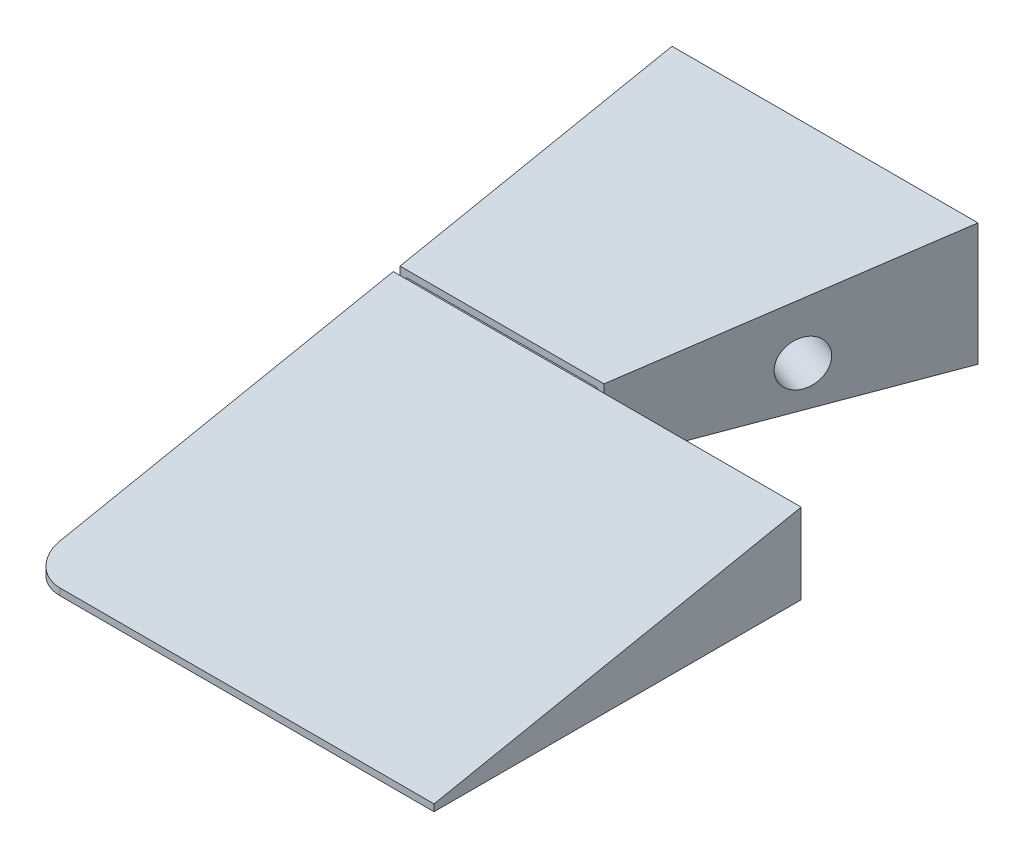
from build123d import *

# Parameters (mm, degrees)
ESBO_O1_W                                      = 130
ESBO_O1_H                                      = 20
RESSALTO_EXTRUS_O1_DEPTH                       = 95
CORTE_EXTRUS_O2_REACH                          = 22
CORTE_EXTRUS_O4_DEPTH                          = 1
CORTE_EXTRUS_O4_DEPTH_BACK                     = 61
BROCA_DE_ROSQUEAR_DE_CANO_PARA_TARRAXA_D_D     = 6.579997
BROCA_DE_ROSQUEAR_DE_CANO_PARA_TARRAXA_D_DEPTH = 10
BROCA_DE_ROSQUEAR_DE_CANO_PARA_TARRAXA_D_TIP   = 1.976830535
BROCA_DE_ROSQUEAR_DE_CANO_PARA_TARRA_2_D       = 6.579997
BROCA_DE_ROSQUEAR_DE_CANO_PARA_TARRA_2_DEPTH   = 10
BROCA_DE_ROSQUEAR_DE_CANO_PARA_TARRA_2_TIP     = 1.976830535
FILETE2_R                                      = 5
CORTE_EXTRUS_O10_REACH                         = 62
RESSALTO_EXTRUS_O2_REACH                       = 57
ESBO_O41_W                                     = 28
ESBO_O41_H                                     = 8
ESBO_O42_W                                     = 45
ESBO_O42_H                                     = 2
CORTE_EXTRUS_O11_DEPTH                         = 41


with BuildPart() as part:
    # Esboço1 → Ressalto-extrusão1 (new body)
    with BuildSketch(Plane.XY):
        Rectangle(ESBO_O1_W, ESBO_O1_H)
    extrude(amount=RESSALTO_EXTRUS_O1_DEPTH)

    # Esboço2 → Corte-extrusão2 (cut, up to next)
    with BuildSketch(Plane(origin=(0, 10, 0), x_dir=(1, 0, 0), z_dir=(0, 1, 0)), mode=Mode.PRIVATE) as corte_extrus_o2_sk1:
        Polygon((65, 0), (-20, 0), (-35, -40), (-35, -41), (-5, -41), (-5, -95), (65, -95), align=None)
    corte_extrus_o2_tool1 = extrude(corte_extrus_o2_sk1.sketch, amount=-CORTE_EXTRUS_O2_REACH, mode=Mode.PRIVATE) & part.part
    add(corte_extrus_o2_tool1.solids().sort_by_distance((24.261214, 10, 44.470976))[0], mode=Mode.SUBTRACT)

    # Esboço13 → Corte-extrusão4 (cut, two sides)
    with BuildSketch(Plane.ZY.offset(65)) as corte_extrus_o4_sk:
        Polygon((-200.200134404, 50.040026881), (0, 10), (95, -9), (295.200134404, -49.040026881), (375.280188165, 351.360241926), (-120.120080642, 450.440295688), align=None)
    extrude(amount=CORTE_EXTRUS_O4_DEPTH, mode=Mode.SUBTRACT)
    extrude(corte_extrus_o4_sk.sketch, amount=-CORTE_EXTRUS_O4_DEPTH_BACK, mode=Mode.SUBTRACT)

    # Broca de rosquear de cano para tarraxa d
    with Locations(Plane.ZY.offset(65)):
        with Locations((20, -2)):
            Hole(BROCA_DE_ROSQUEAR_DE_CANO_PARA_TARRAXA_D_D / 2, depth=BROCA_DE_ROSQUEAR_DE_CANO_PARA_TARRAXA_D_DEPTH)
            with Locations((0, 0, -(BROCA_DE_ROSQUEAR_DE_CANO_PARA_TARRAXA_D_DEPTH + BROCA_DE_ROSQUEAR_DE_CANO_PARA_TARRAXA_D_TIP / 2))):  # 118° drill point
                Cone(0, BROCA_DE_ROSQUEAR_DE_CANO_PARA_TARRAXA_D_D / 2, BROCA_DE_ROSQUEAR_DE_CANO_PARA_TARRAXA_D_TIP, mode=Mode.SUBTRACT)

    # Broca de rosquear de cano para tarra 2
    with Locations(Plane(origin=(-17.534246575, 0, -6.575342466), x_dir=(0.351123442, 0, -0.936329178), z_dir=(0.936329178, 0, 0.351123442))):
        with Locations((-27.022468832, -2)):
            Hole(BROCA_DE_ROSQUEAR_DE_CANO_PARA_TARRA_2_D / 2, depth=BROCA_DE_ROSQUEAR_DE_CANO_PARA_TARRA_2_DEPTH)
            with Locations((0, 0, -(BROCA_DE_ROSQUEAR_DE_CANO_PARA_TARRA_2_DEPTH + BROCA_DE_ROSQUEAR_DE_CANO_PARA_TARRA_2_TIP / 2))):  # 118° drill point
                Cone(0, BROCA_DE_ROSQUEAR_DE_CANO_PARA_TARRA_2_D / 2, BROCA_DE_ROSQUEAR_DE_CANO_PARA_TARRA_2_TIP, mode=Mode.SUBTRACT)

    # Filete2
    filete2_edges = [part.edges().sort_by_distance(p)[0] for p in [
        (-65, -9.5, 95),
    ]]
    fillet(filete2_edges, radius=FILETE2_R)

    # Esboço40 → Corte-extrusão10 (cut, up to next)
    with BuildSketch(Plane.ZY.offset(65), mode=Mode.PRIVATE) as corte_extrus_o10_sk1:
        Polygon((41, 1.8), (41, -10), (40, -10), (40, 2), align=None)
    corte_extrus_o10_tool1 = extrude(corte_extrus_o10_sk1.sketch, amount=-CORTE_EXTRUS_O10_REACH, mode=Mode.PRIVATE) & part.part
    add(corte_extrus_o10_tool1.solids().sort_by_distance((-65, -4.04986, 40.498599))[0], mode=Mode.SUBTRACT)

    # Esboço41 → Ressalto-extrusão2 (add, up to next)
    with BuildSketch(Plane.XY.offset(40), mode=Mode.PRIVATE) as ressalto_extrus_o2_sk1:
        with Locations((-50, -3)):
            Rectangle(ESBO_O41_W, ESBO_O41_H)
    ressalto_extrus_o2_tool1 = extrude(ressalto_extrus_o2_sk1.sketch, amount=RESSALTO_EXTRUS_O2_REACH, mode=Mode.PRIVATE) - part.part
    add(ressalto_extrus_o2_tool1.solids().sort_by_distance((-50, -3, 40))[0])

    # Esboço42 → Corte-extrusão11 (cut)
    with BuildSketch(Plane(origin=(0, 0, 0), x_dir=(-1, 0, 0), z_dir=(0, 0, -1))):
        with Locations((42.5, -9)):
            Rectangle(ESBO_O42_W, ESBO_O42_H)
    extrude(amount=-CORTE_EXTRUS_O11_DEPTH, mode=Mode.SUBTRACT)


solid = part.part
